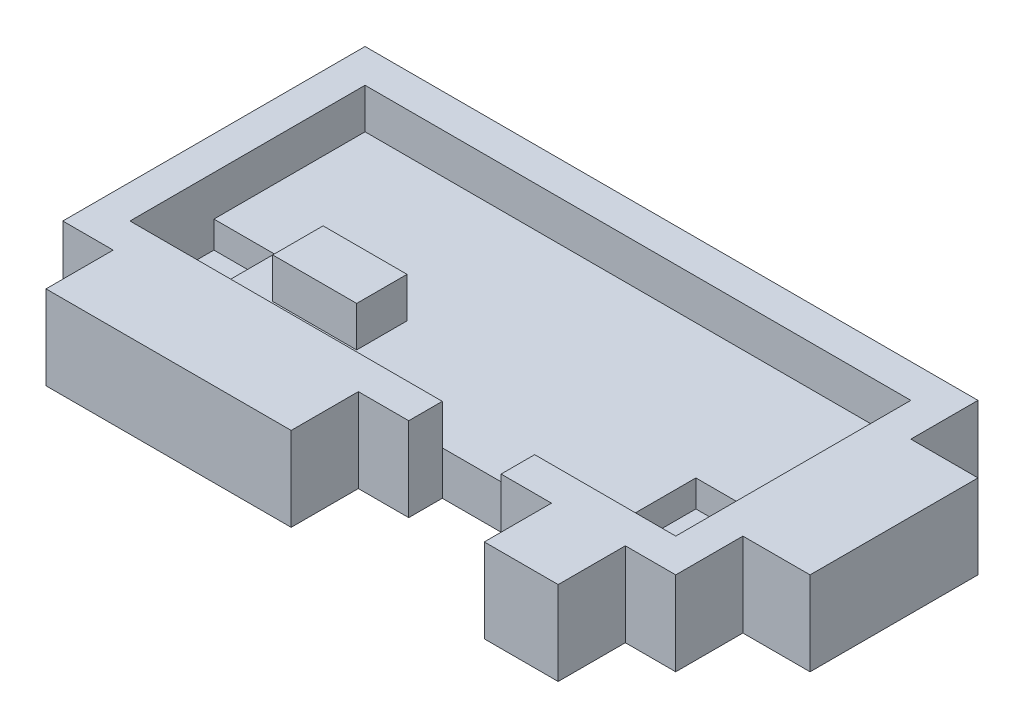
from build123d import *

# Parameters (mm, degrees)
SKETCH1_W           = 36.5
SKETCH1_H           = 18
BOSS_EXTRUDE1_DEPTH = 5
SKETCH2_W           = 32.5
SKETCH2_H           = 14
CUT_EXTRUDE1_DEPTH  = 2.4
SKETCH3_W           = 5
SKETCH3_H           = 3
BOSS_EXTRUDE2_DEPTH = 2.4
CUT_EXTRUDE2_REACH  = 4
SKETCH4_W           = 5.5
SKETCH4_H           = 5
SKETCH5_W           = 3.6
SKETCH5_H           = 5
SKETCH5_W_2         = 4.8
SKETCH5_H_2         = 6
CUT_EXTRUDE3_DEPTH  = 1.6
SKETCH6_W           = 14.6
SKETCH6_H           = 5
SKETCH6_W_2         = 4.4
BOSS_EXTRUDE3_DEPTH = 4
SKETCH7_W           = 10
SKETCH7_H           = 5
BOSS_EXTRUDE4_DEPTH = 4


with BuildPart() as part:
    # Sketch1 → Boss-Extrude1 (new body)
    with BuildSketch(Plane(origin=(0, 0, 0), x_dir=(1, 0, 0), z_dir=(0, 1, 0))):
        with Locations((18.25, 9)):
            Rectangle(SKETCH1_W, SKETCH1_H)
    extrude(amount=-BOSS_EXTRUDE1_DEPTH)

    # Sketch2 → Cut-Extrude1 (cut)
    with BuildSketch(Plane(origin=(0, 0, 0), x_dir=(1, 0, 0), z_dir=(0, 1, 0))):
        with Locations((18.25, 9)):
            Rectangle(SKETCH2_W, SKETCH2_H)
    extrude(amount=-CUT_EXTRUDE1_DEPTH, mode=Mode.SUBTRACT)

    # Sketch3 → Boss-Extrude2 (add)
    with BuildSketch(Plane(origin=(0, -2.4, 0), x_dir=(1, 0, 0), z_dir=(0, 1, 0))):
        with Locations((10.5, 6)):
            Rectangle(SKETCH3_W, SKETCH3_H)
    extrude(amount=BOSS_EXTRUDE2_DEPTH)

    # Sketch4 → Cut-Extrude2 (cut, up to next)
    with BuildSketch(Plane(origin=(0, 0, -2), x_dir=(-1, 0, 0), z_dir=(0, 0, -1)), mode=Mode.PRIVATE) as cut_extrude2_sk1:
        with Locations((-23.35, -2.5)):
            Rectangle(SKETCH4_W, SKETCH4_H)
    cut_extrude2_tool1 = extrude(cut_extrude2_sk1.sketch, amount=-CUT_EXTRUDE2_REACH, mode=Mode.PRIVATE) & part.part
    add(cut_extrude2_tool1.solids().sort_by_distance((23.35, -2.5, -2))[0], mode=Mode.SUBTRACT)

    # Sketch5 → Cut-Extrude3 (cut)
    with BuildSketch(Plane(origin=(0, -2.4, 0), x_dir=(1, 0, 0), z_dir=(0, 1, 0))):
        with Locations((3.8, 4.5)):
            Rectangle(SKETCH5_W, SKETCH5_H)
        with Locations((32.1, 5)):
            Rectangle(SKETCH5_W_2, SKETCH5_H_2)
    extrude(amount=-CUT_EXTRUDE3_DEPTH, mode=Mode.SUBTRACT)

    # Sketch6 → Boss-Extrude3 (add)
    with BuildSketch(Plane.XY):
        with Locations((10.3, -2.5)):
            Rectangle(SKETCH6_W, SKETCH6_H)
        with Locations((31.3, -2.5)):
            Rectangle(SKETCH6_W_2, SKETCH6_H)
    extrude(amount=BOSS_EXTRUDE3_DEPTH)

    # Sketch7 → Boss-Extrude4 (add)
    with BuildSketch(Plane(origin=(36.5, 0, 0), x_dir=(0, 0, -1), z_dir=(1, 0, 0))):
        with Locations((9, -2.5)):
            Rectangle(SKETCH7_W, SKETCH7_H)
    extrude(amount=BOSS_EXTRUDE4_DEPTH)


solid = part.part
